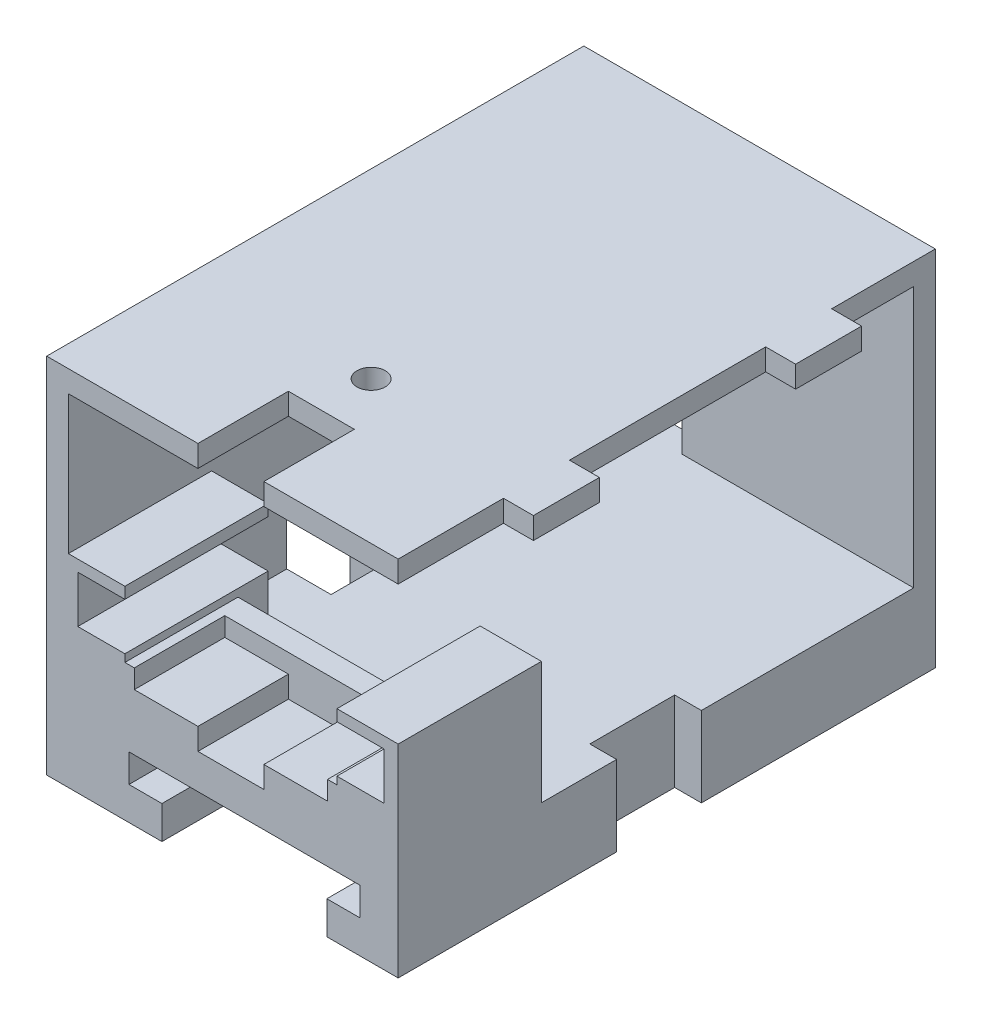
from build123d import *

# Parameters (mm, degrees)
SKETCH1_W               = 53.825
SKETCH1_H               = 38.5
MAIN_EXTRUDE_DEPTH      = 2.3
WALLS_DEPTH             = 35
SKETCH36_W              = 7
SKETCH36_H              = 2.3
SKETCH36_W_2            = 2.3
SKETCH36_H_2            = 7
PUZZLE_MAIN_WALLS_DEPTH = 3.175
SKETCH25_W              = 10.403042977
SKETCH25_H              = 6.605151166
WIRE_HOLE_DEPTH         = 3.3
SKETCH19_W              = 6.5
SKETCH19_H              = 12.025
SKETCH19_W_2            = 6
IR_MOUNT_DEPTH          = 7
MAGNET_MOUNT_HOLE_DEPTH = 51.83
SKETCH40_R              = 1.5
LED_SPACE_DEPTH         = 3
SKETCH42_W              = 7
SKETCH42_H              = 2.3
BOSS_EXTRUDE15_DEPTH    = 3.175
SKETCH44_W              = 6
SKETCH44_H              = 12.025
SKETCH44_W_2            = 6.5
BOSS_EXTRUDE16_DEPTH    = 6
SKETCH45_W              = 5
SKETCH45_H              = 5
IR_PLACEMENT_DEPTH      = 12.025
SKETCH47_R              = 2.5
CUT_EXTRUDE2_DEPTH      = 2
SKETCH48_W              = 7
SKETCH48_H              = 9
CUT_EXTRUDE3_DEPTH      = 15
BOSS_EXTRUDE17_DEPTH    = 3.175
SKETCH51_W              = 22.5
SKETCH51_H              = 10
BOSS_EXTRUDE18_DEPTH    = 4
BOSS_EXTRUDE19_DEPTH    = 6
SKETCH54_W              = 7
SKETCH54_H              = 2.3
CUT_EXTRUDE5_DEPTH      = 9.6


with BuildPart() as part:
    # Sketch1 → main extrude (new body)
    with BuildSketch(Plane(origin=(0, 0, 0), x_dir=(0, 0, -1), z_dir=(1, 0, 0))):
        with Locations((-26.9125, 21.443980352)):
            Rectangle(SKETCH1_W, SKETCH1_H)
    extrude(amount=MAIN_EXTRUDE_DEPTH)

    # Sketch3 → walls (add)
    with BuildSketch(Plane(origin=(2.3, 0, 0), x_dir=(0, 0, -1), z_dir=(1, 0, 0))):
        Polygon((-2.3, 38.393980352), (-2.3, 10.693980352), (-53.825, 10.693980352), (-53.825, 2.193980352), (0, 2.193980352), (0, 40.693980352), (-53.825, 40.693980352), (-53.825, 38.393980352), align=None)
    extrude(amount=WALLS_DEPTH)

    # Sketch36 → Puzzle (main walls) (add)
    with BuildSketch(Plane.XY.offset(53.825)):
        with Locations((11.5, 39.543980352)):
            Rectangle(SKETCH36_W, SKETCH36_H)
        with Locations((26.5, 39.543980352)):
            Rectangle(SKETCH36_W, SKETCH36_H)
        with Locations((1.15, 29.193980352)):
            Rectangle(SKETCH36_W_2, SKETCH36_H_2)
        with Locations((1.15, 14.193980352)):
            Rectangle(SKETCH36_W_2, SKETCH36_H_2)
    extrude(amount=PUZZLE_MAIN_WALLS_DEPTH)

    # Sketch25 → Wire Hole (cut, through all)
    with BuildSketch(Plane.XY.offset(2.3)):
        with Locations((7.501521489, 13.996555935)):
            Rectangle(SKETCH25_W, SKETCH25_H)
    extrude(amount=-WIRE_HOLE_DEPTH, mode=Mode.SUBTRACT)

    # Sketch19 → IR mount (add)
    with BuildSketch(Plane(origin=(0, 10.693980352, 0), x_dir=(1, 0, 0), z_dir=(0, 1, 0))):
        with Locations((34.05, -47.8125)):
            Rectangle(SKETCH19_W, SKETCH19_H)
        with Locations((5.3, -47.8125)):
            Rectangle(SKETCH19_W_2, SKETCH19_H)
    extrude(amount=IR_MOUNT_DEPTH)

    # Sketch24 → Magnet Mount Hole (cut)
    with BuildSketch(Plane.XY.offset(53.83)):
        Polygon((12.23, 2.193980352), (29.73, 2.193980352), (29.73, 5.693980352), (33.23, 5.693980352), (33.23, 8.693980352), (8.73, 8.693980352), (8.73, 5.693980352), (12.23, 5.693980352), align=None)
    extrude(amount=-MAGNET_MOUNT_HOLE_DEPTH, mode=Mode.SUBTRACT)

    # Sketch40 → LED Space (cut)
    with BuildSketch(Plane(origin=(0, 40.693980352, 0), x_dir=(1, 0, 0), z_dir=(0, 1, 0))):
        with Locations((19.3, -41.872631961)):
            Circle(SKETCH40_R)
    extrude(amount=-LED_SPACE_DEPTH, mode=Mode.SUBTRACT)

    # Sketch42 → Boss-Extrude15 (add)
    with BuildSketch(Plane(origin=(37.3, 0, 0), x_dir=(0, 0, -1), z_dir=(1, 0, 0))):
        with Locations((-42.325, 39.543980352)):
            Rectangle(SKETCH42_W, SKETCH42_H)
        with Locations((-14.5, 39.543980352)):
            Rectangle(SKETCH42_W, SKETCH42_H)
    extrude(amount=BOSS_EXTRUDE15_DEPTH)

    # Sketch44 → Boss-Extrude16 (add)
    with BuildSketch(Plane(origin=(0, 17.693980352, 0), x_dir=(1, 0, 0), z_dir=(0, 1, 0))):
        with Locations((5.3, -47.8125)):
            Rectangle(SKETCH44_W, SKETCH44_H)
        with Locations((34.05, -47.8125)):
            Rectangle(SKETCH44_W_2, SKETCH44_H)
    extrude(amount=BOSS_EXTRUDE16_DEPTH)

    # Sketch45 → IR placement (cut)
    with BuildSketch(Plane.XY.offset(53.825)):
        with Locations((33.3, 19.993980352)):
            Rectangle(SKETCH45_W, SKETCH45_H)
        with Locations((5.8, 19.993980352)):
            Rectangle(SKETCH45_W, SKETCH45_H)
    extrude(amount=-IR_PLACEMENT_DEPTH, mode=Mode.SUBTRACT)

    # Sketch47 → Cut-Extrude2 (cut)
    with BuildSketch(Plane(origin=(0, 0, 0), x_dir=(-1, 0, 0), z_dir=(0, 0, -1))):
        with Locations((-21.018982331, 5.262699137)):
            Circle(SKETCH47_R)
    extrude(amount=-CUT_EXTRUDE2_DEPTH, mode=Mode.SUBTRACT)

    # Sketch48 → Cut-Extrude3 (cut)
    with BuildSketch(Plane.XZ.offset(-2.193980352)):
        with Locations((3.5, 29.325)):
            Rectangle(SKETCH48_W, SKETCH48_H)
        with Locations((37.962462444, 29.325)):
            Rectangle(SKETCH48_W, SKETCH48_H)
    extrude(amount=-CUT_EXTRUDE3_DEPTH, mode=Mode.SUBTRACT)

    # Sketch50 → Boss-Extrude17 (add)
    with BuildSketch(Plane.XY.offset(53.825)):
        Polygon((37.3, 38.393980352), (2.3, 38.393980352), (2.3, 23.693980352), (8.3, 23.693980352), (8.3, 22.493980352), (3.3, 22.493980352), (3.3, 17.493980352), (8.3, 17.493980352), (8.3, 10.693980352), (30.8, 10.693980352), (30.8, 17.493980352), (35.8, 17.493980352), (35.8, 22.493980352), (30.8, 22.493980352), (30.8, 23.693980352), (37.3, 23.693980352), (37.3, 2.193980352), (29.73, 2.193980352), (29.73, 5.693980352), (33.23, 5.693980352), (33.23, 8.693980352), (8.73, 8.693980352), (8.73, 5.693980352), (12.23, 5.693980352), (12.23, 2.193980352), (0, 2.193980352), (0, 40.693980352), (37.3, 40.693980352), align=None)
    extrude(amount=BOSS_EXTRUDE17_DEPTH)

    # Sketch51 → Boss-Extrude18 (add)
    with BuildSketch(Plane(origin=(0, 10.693980352, 0), x_dir=(1, 0, 0), z_dir=(0, 1, 0))):
        with Locations((19.55, -52)):
            Rectangle(SKETCH51_W, SKETCH51_H)
    extrude(amount=BOSS_EXTRUDE18_DEPTH)

    # Sketch52 → Boss-Extrude19 (add)
    with BuildSketch(Plane(origin=(0, 10.693980352, 0), x_dir=(1, 0, 0), z_dir=(0, 1, 0))):
        Polygon((9.3, -47.4), (29.8, -47.4), (29.8, -57), (30.8, -57), (30.8, -47), (30.8, -45), (8.3, -45), (8.3, -47), (8.3, -57), (9.3, -57), align=None)
    extrude(amount=BOSS_EXTRUDE19_DEPTH)

    # Sketch54 → Cut-Extrude5 (cut)
    with BuildSketch(Plane.XY.offset(57)):
        with Locations((19.55, 39.543980352)):
            Rectangle(SKETCH54_W, SKETCH54_H)
        with Locations((19.55, 13.543980352)):
            Rectangle(SKETCH54_W, SKETCH54_H)
    extrude(amount=-CUT_EXTRUDE5_DEPTH, mode=Mode.SUBTRACT)


solid = part.part
